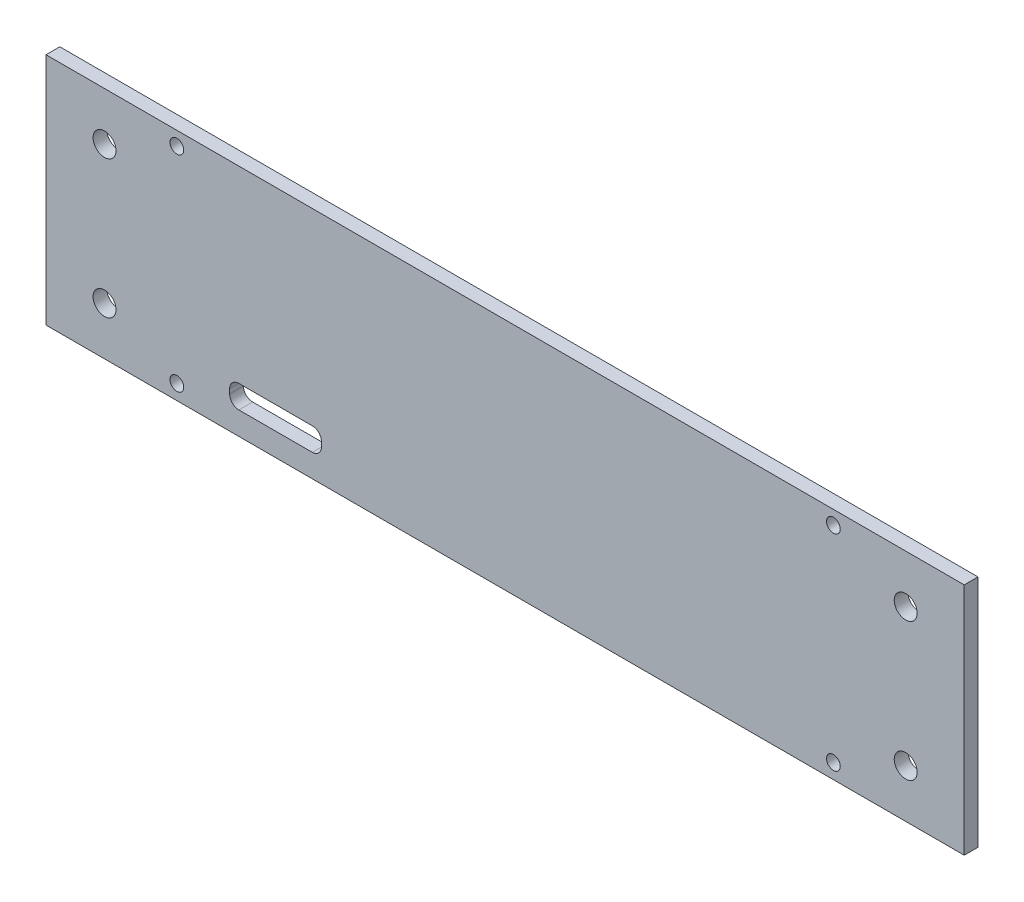
from build123d import *

# Parameters (mm, degrees)
SKETCH1_W           = 200
SKETCH1_H           = 51
BOSS_EXTRUDE1_DEPTH = 3
SKETCH2_R           = 1.5
SKETCH2_R_2         = 2.5
CUT_EXTRUDE1_DEPTH  = 3
SKETCH3_W           = 20
SKETCH3_H           = 5
CUT_EXTRUDE2_DEPTH  = 3
FILLET1_R           = 2


with BuildPart() as part:
    # Sketch1 → Boss-Extrude1 (new body)
    with BuildSketch(Plane.XY):
        with Locations((100, 25.5)):
            Rectangle(SKETCH1_W, SKETCH1_H)
    extrude(amount=BOSS_EXTRUDE1_DEPTH)

    # Sketch2 → Cut-Extrude1 (cut)
    with BuildSketch(Plane.XY.offset(3)):
        with Locations((28.5, 48)):
            Circle(SKETCH2_R)
        with Locations((28.5, 3.25)):
            Circle(SKETCH2_R)
        with Locations((12.75, 40.5)):
            Circle(SKETCH2_R_2)
        with Locations((12.75, 10.5)):
            Circle(SKETCH2_R_2)
        with Locations((187.25, 40.5)):
            Circle(SKETCH2_R_2)
        with Locations((187.25, 10.5)):
            Circle(SKETCH2_R_2)
        with Locations((171.5, 3.25)):
            Circle(SKETCH2_R)
        with Locations((171.5, 48)):
            Circle(SKETCH2_R)
    extrude(amount=-CUT_EXTRUDE1_DEPTH, mode=Mode.SUBTRACT)

    # Sketch3 → Cut-Extrude2 (cut)
    with BuildSketch(Plane.XY.offset(3)):
        with Locations((50, 7.5)):
            Rectangle(SKETCH3_W, SKETCH3_H)
    extrude(amount=-CUT_EXTRUDE2_DEPTH, mode=Mode.SUBTRACT)

    # Fillet1
    fillet1_edges = [part.edges().sort_by_distance(p)[0] for p in [
        (40, 5, 1.5),
        (40, 10, 1.5),
        (60, 10, 1.5),
        (60, 5, 1.5),
    ]]
    fillet(fillet1_edges, radius=FILLET1_R)


solid = part.part
